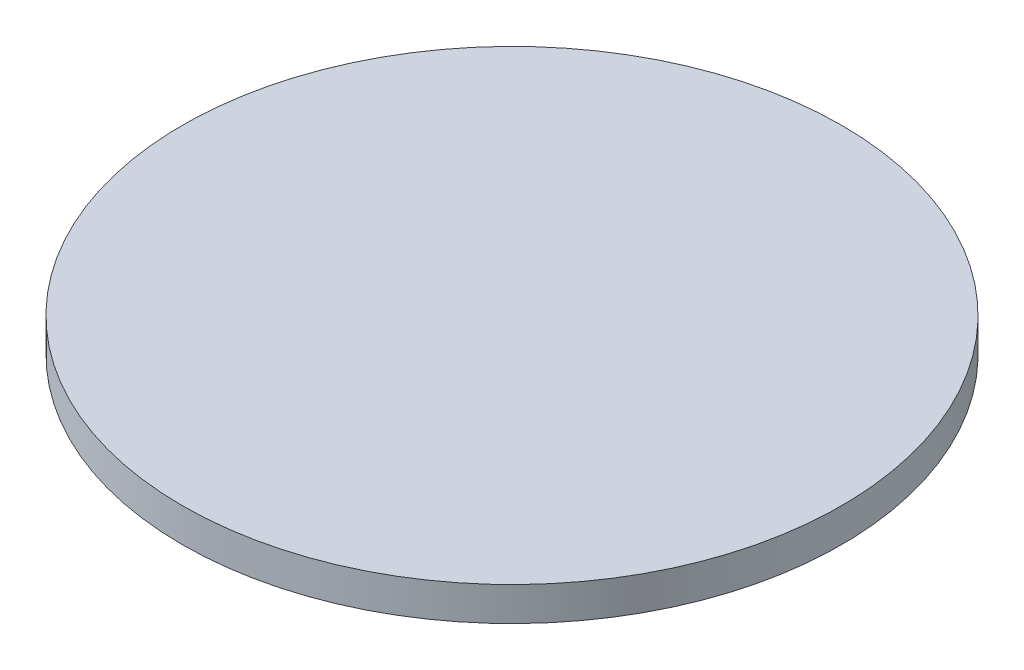
from build123d import *

# Parameters (mm, degrees)
SKETCH1_R           = 19.5
BOSS_EXTRUDE1_DEPTH = 2


with BuildPart() as part:
    # Sketch1 → Boss-Extrude1 (new body)
    with BuildSketch(Plane(origin=(0, 0, 0), x_dir=(1, 0, 0), z_dir=(0, 1, 0))):
        Circle(SKETCH1_R)
    extrude(amount=BOSS_EXTRUDE1_DEPTH)


solid = part.part
